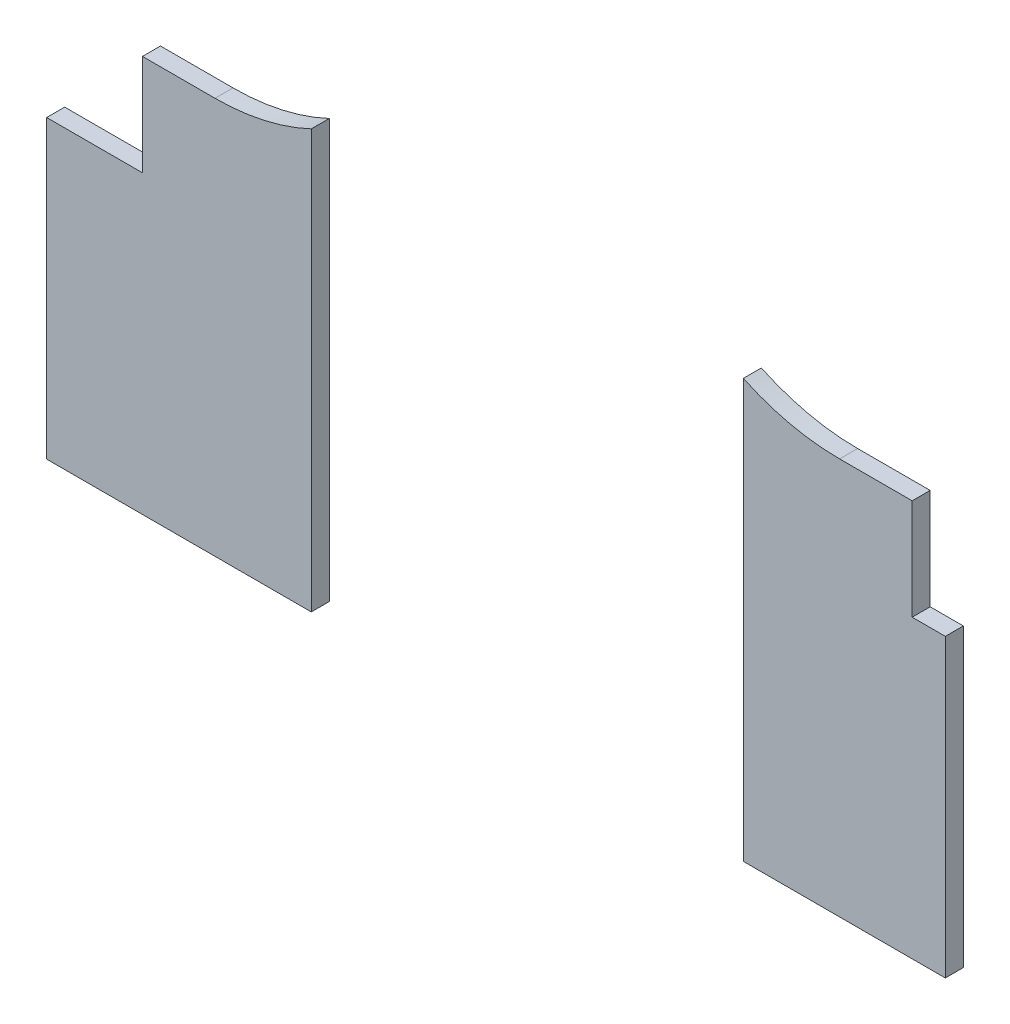
from build123d import *

# Parameters (mm, degrees)
SKETCH1_W           = 249.6
SKETCH1_H           = 267.4
BOSS_EXTRUDE1_DEPTH = 5
SKETCH5_W           = 249.6
SKETCH5_H           = 71.838779628
CUT_EXTRUDE3_DEPTH  = 6
SKETCH7_W           = 120
SKETCH7_H           = 195.561220372
CUT_EXTRUDE4_DEPTH  = 6


with BuildPart() as part:
    # Sketch1 → Boss-Extrude1 (new body)
    with BuildSketch(Plane.XY):
        with Locations((124.8, -133.7)):
            Rectangle(SKETCH1_W, SKETCH1_H)
    extrude(amount=BOSS_EXTRUDE1_DEPTH)

    # Sketch5 → Cut-Extrude3 (cut, through all)
    with BuildSketch(Plane.XY.offset(5)):
        with Locations((124.8, -231.480610186)):
            Rectangle(SKETCH5_W, SKETCH5_H)
        with BuildLine():
            Line((162.086136524, 0), (249.6, 0))
            Line((249.6, 0), (249.6, -113.374891146))
            Line((249.6, -113.374891146), (240.395661642, -113.374891146))
            Line((240.395661642, -113.374891146), (240.395661642, -85.374891146))
            Line((240.395661642, -85.374891146), (220.249607492, -85.374891146))
            ThreePointArc((220.249607492, -85.374891146), (168.597256642, -58.064160131), (162.086136524, 0))
        make_face()
        with BuildLine():
            Line((104.913863476, 0), (0, 0))
            Line((0, 0), (0, -113.374891146))
            Line((0, -113.374891146), (26.604338358, -113.374891146))
            Line((26.604338358, -113.374891146), (26.604338358, -85.374891146))
            Line((26.604338358, -85.374891146), (46.750392508, -85.374891146))
            ThreePointArc((46.750392508, -85.374891146), (98.402743358, -58.064160131), (104.913863476, 0))
        make_face()
    extrude(amount=-CUT_EXTRUDE3_DEPTH, mode=Mode.SUBTRACT)

    # Sketch7 → Cut-Extrude4 (cut, through all)
    with BuildSketch(Plane.XY.offset(5)):
        with Locations((133.5, -97.780610186)):
            Rectangle(SKETCH7_W, SKETCH7_H)
    extrude(amount=-CUT_EXTRUDE4_DEPTH, mode=Mode.SUBTRACT)


solid = part.part
